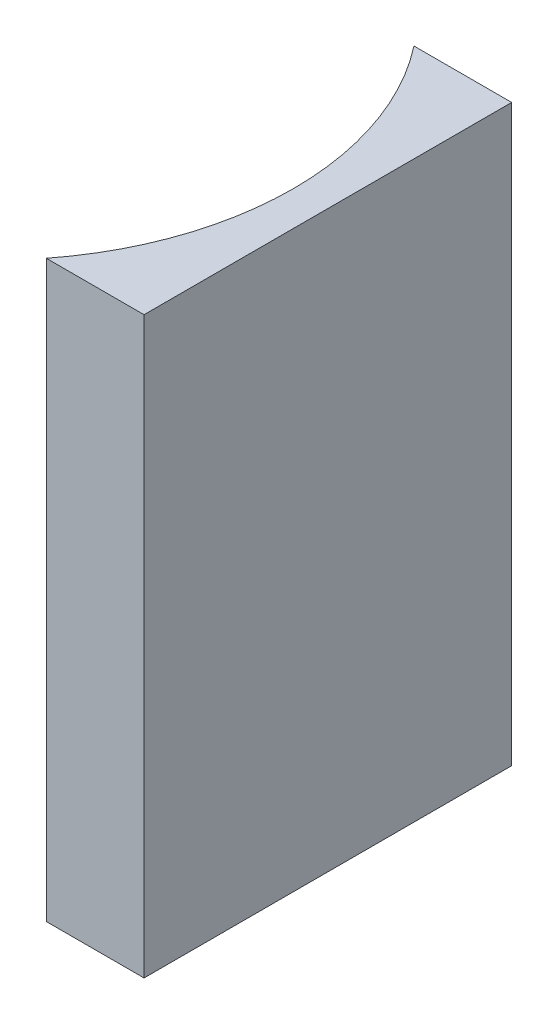
from build123d import *

# Parameters (mm, degrees)
EXTRUDE_1_DEPTH = 25


with BuildPart() as part:
    # 草图1 → 凸台-拉伸1 (new body)
    with BuildSketch(Plane(origin=(0, 0, 0), x_dir=(1, 0, 0), z_dir=(0, 1, 0))):
        with BuildLine():
            Line((0, 0), (0, -16))
            Line((0, -16), (-4.253049234, -16))
            ThreePointArc((-4.253049234, -16), (-1.5, -8), (-4.253049234, 0))
            Line((-4.253049234, 0), (0, 0))
        make_face()
    extrude(amount=EXTRUDE_1_DEPTH)


solid = part.part
